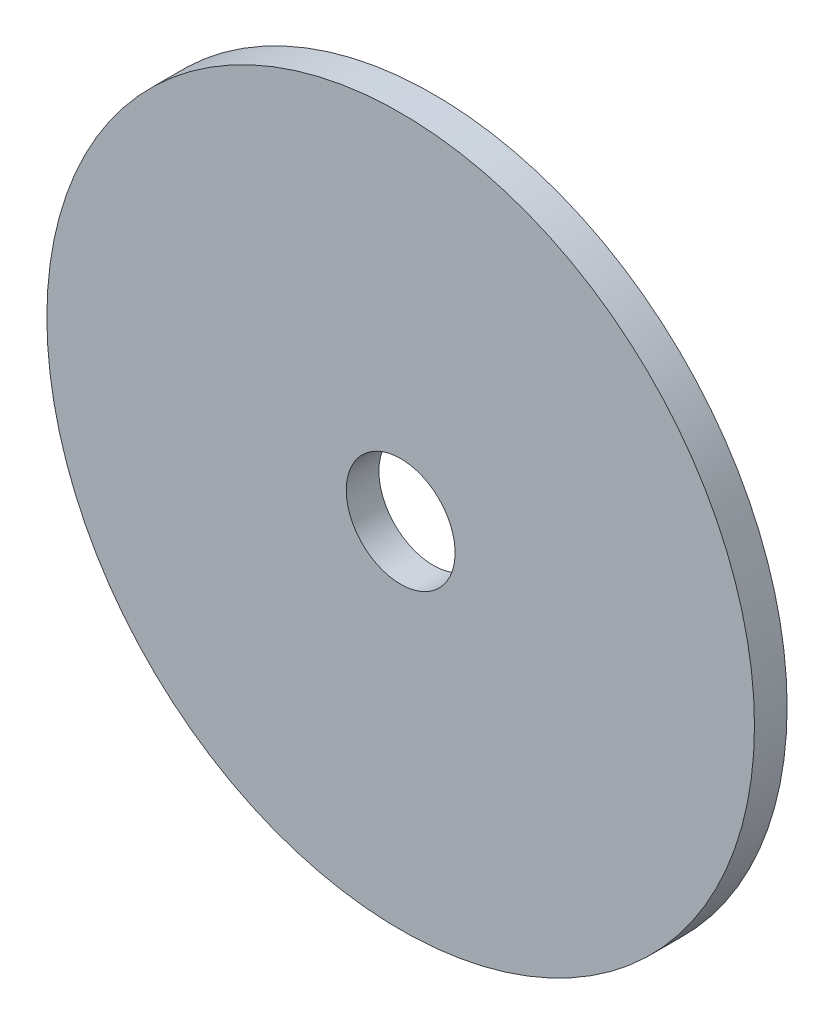
from build123d import *

# Parameters (mm, degrees)
SKETCH1_R           = 65
BOSS_EXTRUDE1_DEPTH = 6
SKETCH4_R           = 10
CUT_EXTRUDE3_DEPTH  = 7


with BuildPart() as part:
    # Sketch1 → Boss-Extrude1 (new body)
    with BuildSketch(Plane.XY):
        Circle(SKETCH1_R)
    extrude(amount=BOSS_EXTRUDE1_DEPTH)

    # Sketch4 → Cut-Extrude3 (cut, through all)
    with BuildSketch(Plane(origin=(0, 0, 0), x_dir=(-1, 0, 0), z_dir=(0, 0, -1))):
        Circle(SKETCH4_R)
    extrude(amount=-CUT_EXTRUDE3_DEPTH, mode=Mode.SUBTRACT)


solid = part.part
